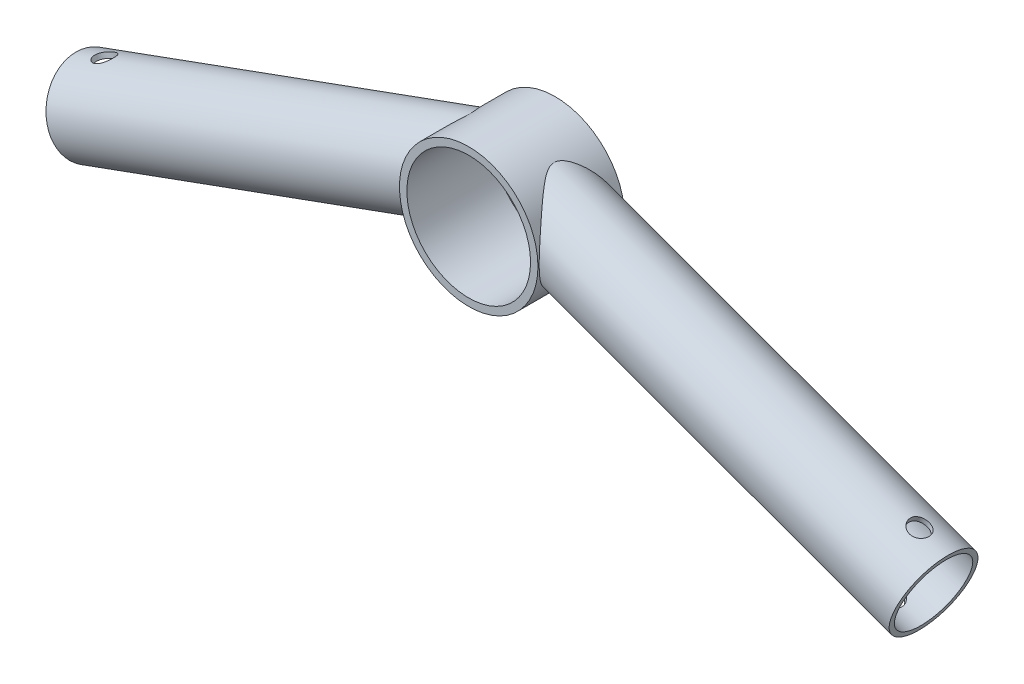
from build123d import *

# Parameters (mm, degrees)
SKETCH1_R                = 28
SKETCH1_R_2              = 25
BOSS_EXTRUDE1_DEPTH      = 35
BOSS_EXTRUDE2_REACH      = 219.227
BOSS_EXTRUDE2_END_RADIUS = 28
SKETCH3_R                = 17
SKETCH3_R_2              = 15
SKETCH4_R                = 4
CUT_EXTRUDE1_DEPTH       = 211.243311002


with BuildPart() as part:
    # Sketch1 → Boss-Extrude1 (new body)
    with BuildSketch(Plane.XY):
        Circle(SKETCH1_R)
        Circle(SKETCH1_R_2, mode=Mode.SUBTRACT)
    extrude(amount=BOSS_EXTRUDE1_DEPTH)

    # Boss-Extrude2: up to this cylinder (the profile starts outside it)
    boss_extrude2_end = Plane(origin=(0, 0, 17.5), z_dir=(0, 0, -1)) * Cylinder(BOSS_EXTRUDE2_END_RADIUS, 495.454, mode=Mode.PRIVATE)
    # Sketch3 → Boss-Extrude2 (add, up to the surface)
    with BuildSketch(Plane(origin=(167.121481691, -60.827244842, 0), x_dir=(0, 0, -1), z_dir=(0.9396926207859082, -0.34202014332566943, 0)), mode=Mode.PRIVATE) as boss_extrude2_sk1:
        with Locations(Location((-17.5, 9.707828641, 0), (0, 0, 90))):
            Circle(SKETCH3_R)
        with Locations(Location((-17.5, 9.707828641, 0), (0, 0, 90))):
            Circle(SKETCH3_R_2, mode=Mode.SUBTRACT)
    boss_extrude2_tool1 = extrude(boss_extrude2_sk1.sketch, amount=-BOSS_EXTRUDE2_REACH, mode=Mode.PRIVATE) - boss_extrude2_end
    boss_extrude2 = boss_extrude2_tool1.solids().sort_by_distance((164.791867, -67.22781, 17.5))[0]
    add(boss_extrude2)

    # Mirror1: Boss-Extrude2 across plane
    add(boss_extrude2.mirror(Plane(origin=(0, 0, 0), x_dir=(0, 0, 1), z_dir=(1, 0, 0))))

    # Sketch4 → Cut-Extrude1 (cut, through all)
    with BuildSketch(Plane(origin=(9.13461538, 25.097149491, 0), x_dir=(0.9396926207859082, -0.34202014332566943, 0), z_dir=(0.34202014332566943, 0.9396926207859082, 0))):
        with Locations(Location((165.707576324, -17.5, 0), (0, 0, 180))):
            Circle(SKETCH4_R)
    cut_extrude1 = extrude(amount=-CUT_EXTRUDE1_DEPTH, mode=Mode.SUBTRACT)

    # Mirror2: Cut-Extrude1 across plane
    add(cut_extrude1.mirror(Plane(origin=(0, 0, 0), x_dir=(0, 0, 1), z_dir=(1, 0, 0))), mode=Mode.SUBTRACT)


solid = part.part
